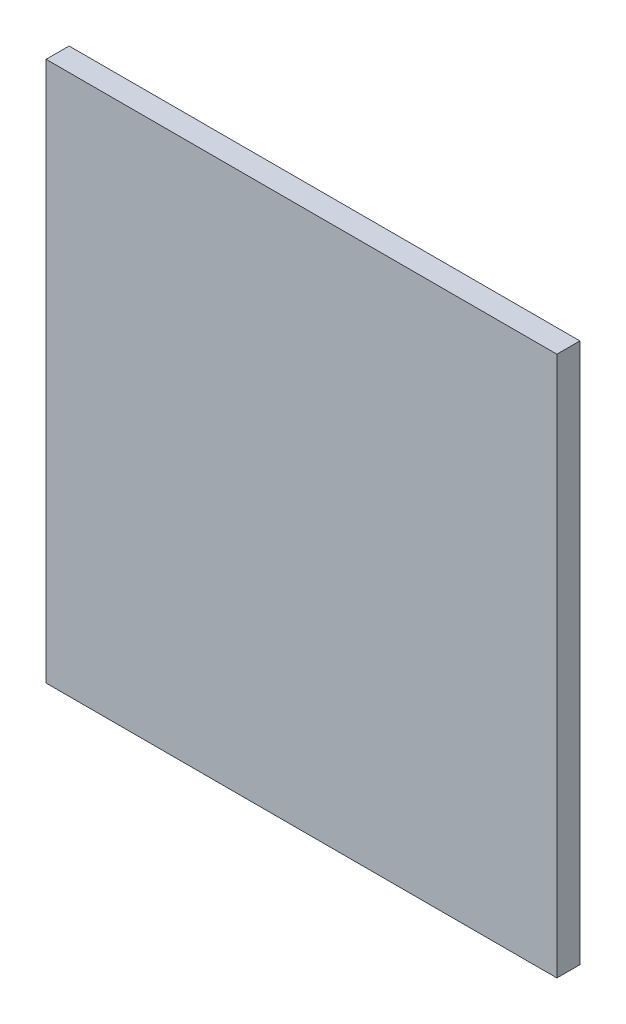
from build123d import *

# Parameters (mm, degrees)
SKETCH1_W           = 55.5
SKETCH1_H           = 58.7
BOSS_EXTRUDE1_DEPTH = 2.5


with BuildPart() as part:
    # Sketch1 → Boss-Extrude1 (new body)
    with BuildSketch(Plane.XY):
        Rectangle(SKETCH1_W, SKETCH1_H)
    extrude(amount=BOSS_EXTRUDE1_DEPTH)


solid = part.part
